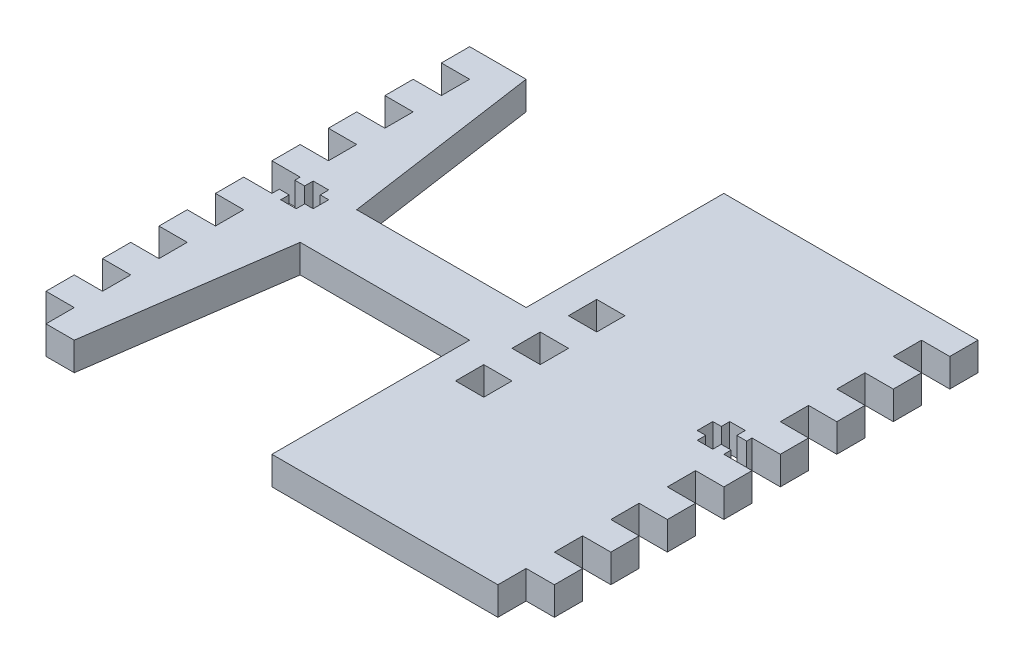
from build123d import *

# Parameters (mm, degrees)
ESQUISSE1_W                     = 80
ESQUISSE1_H                     = 80
BOSS_EXTRU_1_DEPTH              = 5
ESQUISSE2_W                     = 5
ESQUISSE2_H                     = 5
BOSS_EXTRU_2_DEPTH              = 5
R_P_TITION_LIN_AIRE1_COUNT      = 2
R_P_TITION_LIN_AIRE1_PITCH      = 85
R_P_TITION_LIN_AIRE1_COUNT_DIR2 = 8
R_P_TITION_LIN_AIRE1_PITCH_DIR2 = 10
ENL_V_MAT_EXTRU_1_DEPTH         = 10
ESQUISSE9_W                     = 5
ESQUISSE9_H                     = 5
ENL_V_MAT_EXTRU_6_DEPTH         = 10
R_P_TITION_LIN_AIRE4_COUNT      = 2
R_P_TITION_LIN_AIRE4_PITCH      = 10
R_P_TITION_LIN_AIRE4_COL_COUNT  = 2
R_P_TITION_LIN_AIRE4_COL_PITCH  = 10
ENL_V_MAT_EXTRU_7_DEPTH         = 10


with BuildPart() as part:
    # Esquisse1 → Boss.-Extru.1 (new body)
    with BuildSketch(Plane(origin=(0, 0, 0), x_dir=(1, 0, 0), z_dir=(0, 1, 0))):
        Rectangle(ESQUISSE1_W, ESQUISSE1_H)
    extrude(amount=BOSS_EXTRU_1_DEPTH)

    # Esquisse2 → Boss.-Extru.2 (add)
    with BuildSketch(Plane(origin=(0, 5, 0), x_dir=(1, 0, 0), z_dir=(0, 1, 0))):
        with Locations((-42.5, 37.5)):
            Rectangle(ESQUISSE2_W, ESQUISSE2_H)
    boss_extru_2 = extrude(amount=-BOSS_EXTRU_2_DEPTH)

    # Répétition linéaire1: Boss.-Extru.2 2 × 8
    with Locations(*[(i * R_P_TITION_LIN_AIRE1_PITCH, 0, j * R_P_TITION_LIN_AIRE1_PITCH_DIR2) for i in range(R_P_TITION_LIN_AIRE1_COUNT) for j in range(R_P_TITION_LIN_AIRE1_COUNT_DIR2) if (i, j) != (0, 0)]):
        add(boss_extru_2)

    # Esquisse3 → Enlèv. mat.-Extru.1 (cut)
    with BuildSketch(Plane(origin=(0, 5, 0), x_dir=(1, 0, 0), z_dir=(0, 1, 0))):
        Polygon((40, 4.05), (38.25, 4.05), (38.25, 5.55), (35.5, 5.55), (35.5, 4.05), (34, 4.05), (34, 1.3), (35.5, 1.3), (35.5, -0.2), (38.25, -0.2), (38.25, 1.3), (40, 1.3), align=None)
    enl_v_mat_extru_1 = extrude(amount=-ENL_V_MAT_EXTRU_1_DEPTH, mode=Mode.SUBTRACT)

    # Esquisse9 → Enlèv. mat.-Extru.6 (cut)
    with BuildSketch(Plane(origin=(0, 5, 0), x_dir=(1, 0, 0), z_dir=(0, 1, 0))):
        with Locations((7.5, 0)):
            Rectangle(ESQUISSE9_W, ESQUISSE9_H)
    enl_v_mat_extru_6 = extrude(amount=-ENL_V_MAT_EXTRU_6_DEPTH, mode=Mode.SUBTRACT)

    # Répétition linéaire4: Enlèv. mat.-Extru.6 ×2
    with Locations(*[(0, 0, -i * R_P_TITION_LIN_AIRE4_PITCH) for i in range(1, R_P_TITION_LIN_AIRE4_COUNT)]):
        add(enl_v_mat_extru_6, mode=Mode.SUBTRACT)

    # Répétition linéaire4 col: Enlèv. mat.-Extru.6 ×2
    with Locations(*[(0, 0, i * R_P_TITION_LIN_AIRE4_COL_PITCH) for i in range(1, R_P_TITION_LIN_AIRE4_COL_COUNT)]):
        add(enl_v_mat_extru_6, mode=Mode.SUBTRACT)

    # Symétrie3: Enlèv. mat.-Extru.1 across plane
    add(enl_v_mat_extru_1.mirror(Plane(origin=(0, 0, 0), x_dir=(0, 0, 1), z_dir=(1, 0, 0))), mode=Mode.SUBTRACT)

    # Esquisse7 → Enlèv. mat.-Extru.7 (cut)
    with BuildSketch(Plane(origin=(0, 5, 0), x_dir=(1, 0, 0), z_dir=(0, 1, 0))):
        Polygon((-35, 40), (0, 40), (0, 5), (-30, 5), align=None)
        Polygon((-35, -40), (0, -40), (0, -5), (-30, -5), align=None)
    extrude(amount=-ENL_V_MAT_EXTRU_7_DEPTH, mode=Mode.SUBTRACT)


solid = part.part
